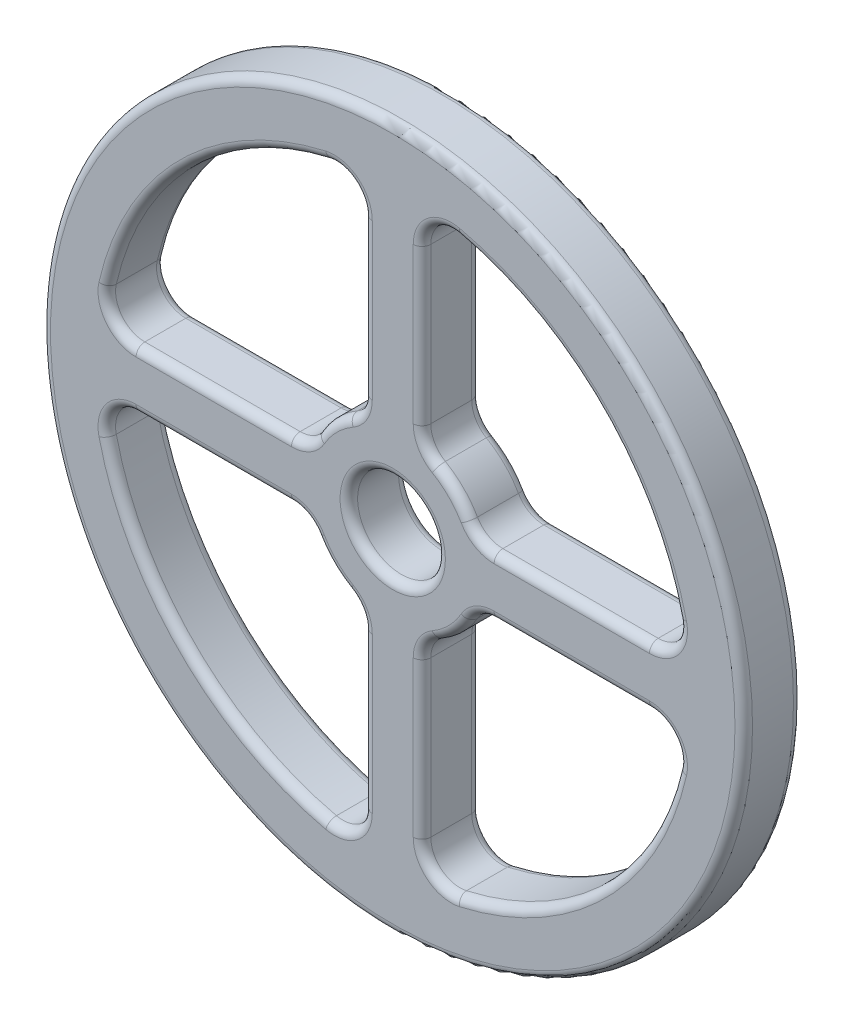
from build123d import *

# Parameters (mm, degrees)
SKETCH2_R               = 120
SKETCH2_R_2             = 15
BOSS_EXTRUDE1_DEPTH     = 10
CUT_EXTRUDE1_DEPTH      = 1
CUT_EXTRUDE1_DEPTH_BACK = 21
FILLET1_R               = 3


with BuildPart() as part:
    # Sketch2 → Boss-Extrude1 (new body, symmetric)
    with BuildSketch(Plane.XY):
        Circle(SKETCH2_R)
        Circle(SKETCH2_R_2, mode=Mode.SUBTRACT)
    extrude(amount=BOSS_EXTRUDE1_DEPTH, both=True)

    # Sketch3 → Cut-Extrude1 (cut, two sides)
    with BuildSketch(Plane.XY.offset(10)) as cut_extrude1_sk:
        with BuildLine():
            Line((-10, -87.749643874), (-10, -34.641016151))
            ThreePointArc((-10, -34.641016151), (-11.339745962, -29.641016151), (-15, -25.980762114))
            ThreePointArc((-15, -25.980762114), (-21.213203436, -21.213203436), (-25.980762114, -15))
            ThreePointArc((-25.980762114, -15), (-29.641016151, -11.339745962), (-34.641016151, -10))
            Line((-34.641016151, -10), (-87.749643874, -10))
            ThreePointArc((-87.749643874, -10), (-95.567003474, -13.763904355), (-97.499604304, -22.222222222))
            ThreePointArc((-97.499604304, -22.222222222), (-70.710678119, -70.710678119), (-22.222222222, -97.499604304))
            ThreePointArc((-22.222222222, -97.499604304), (-13.763904355, -95.567003474), (-10, -87.749643874))
        make_face()
        with BuildLine():
            Line((10, -87.749643874), (10, -34.641016151))
            ThreePointArc((10, -34.641016151), (11.339745962, -29.641016151), (15, -25.980762114))
            ThreePointArc((15, -25.980762114), (21.213203436, -21.213203436), (25.980762114, -15))
            ThreePointArc((25.980762114, -15), (29.641016151, -11.339745962), (34.641016151, -10))
            Line((34.641016151, -10), (87.749643874, -10))
            ThreePointArc((87.749643874, -10), (95.567003474, -13.763904355), (97.499604304, -22.222222222))
            ThreePointArc((97.499604304, -22.222222222), (70.710678119, -70.710678119), (22.222222222, -97.499604304))
            ThreePointArc((22.222222222, -97.499604304), (13.763904355, -95.567003474), (10, -87.749643874))
        make_face()
        with BuildLine():
            Line((10, 87.749643874), (10, 34.641016151))
            ThreePointArc((10, 34.641016151), (11.339745962, 29.641016151), (15, 25.980762114))
            ThreePointArc((15, 25.980762114), (21.213203436, 21.213203436), (25.980762114, 15))
            ThreePointArc((25.980762114, 15), (29.641016151, 11.339745962), (34.641016151, 10))
            Line((34.641016151, 10), (87.749643874, 10))
            ThreePointArc((87.749643874, 10), (95.567003474, 13.763904355), (97.499604304, 22.222222222))
            ThreePointArc((97.499604304, 22.222222222), (70.710678119, 70.710678119), (22.222222222, 97.499604304))
            ThreePointArc((22.222222222, 97.499604304), (13.763904355, 95.567003474), (10, 87.749643874))
        make_face()
        with BuildLine():
            Line((-34.641016151, 10), (-87.749643874, 10))
            ThreePointArc((-87.749643874, 10), (-95.567003474, 13.763904355), (-97.499604304, 22.222222222))
            ThreePointArc((-97.499604304, 22.222222222), (-70.710678119, 70.710678119), (-22.222222222, 97.499604304))
            ThreePointArc((-22.222222222, 97.499604304), (-13.763904355, 95.567003474), (-10, 87.749643874))
            Line((-10, 87.749643874), (-10, 34.641016151))
            ThreePointArc((-10, 34.641016151), (-11.339745962, 29.641016151), (-15, 25.980762114))
            ThreePointArc((-15, 25.980762114), (-21.213203436, 21.213203436), (-25.980762114, 15))
            ThreePointArc((-25.980762114, 15), (-29.641016151, 11.339745962), (-34.641016151, 10))
        make_face()
    extrude(amount=CUT_EXTRUDE1_DEPTH, mode=Mode.SUBTRACT)
    extrude(cut_extrude1_sk.sketch, amount=-CUT_EXTRUDE1_DEPTH_BACK, mode=Mode.SUBTRACT)

    # Fillet1
    fillet1_edges = [part.edges().sort_by_distance(p)[0] for p in [
        (-120, 0, -10),
        (-13.763904355, 95.567003474, 10),
        (-11.339745962, 29.641016151, 10),
        (-21.213203436, 21.213203436, 10),
        (-29.641016151, 11.339745962, 10),
        (-95.567003474, 13.763904355, 10),
        (-70.710678119, 70.710678119, 10),
        (-13.763904355, 95.567003474, -10),
        (-10, 61.195330013, -10),
        (-11.339745962, 29.641016151, -10),
        (-21.213203436, 21.213203436, -10),
        (-29.641016151, 11.339745962, -10),
        (-61.195330013, 10, -10),
        (-95.567003474, 13.763904355, -10),
        (-70.710678119, 70.710678119, -10),
        (-61.195330013, 10, 10),
        (-10, 61.195330013, 10),
        (-120, 0, 10),
        (-15, 0, -10),
        (-15, 0, 10),
        (13.763904355, 95.567003474, 10),
        (70.710678119, 70.710678119, 10),
        (95.567003474, 13.763904355, 10),
        (29.641016151, 11.339745962, 10),
        (21.213203436, 21.213203436, 10),
        (11.339745962, 29.641016151, 10),
        (13.763904355, 95.567003474, -10),
        (70.710678119, 70.710678119, -10),
        (95.567003474, 13.763904355, -10),
        (61.195330013, 10, -10),
        (29.641016151, 11.339745962, -10),
        (21.213203436, 21.213203436, -10),
        (11.339745962, 29.641016151, -10),
        (10, 61.195330013, -10),
        (10, 61.195330013, 10),
        (61.195330013, 10, 10),
        (95.567003474, -13.763904355, 10),
        (70.710678119, -70.710678119, 10),
        (13.763904355, -95.567003474, 10),
        (11.339745962, -29.641016151, 10),
        (21.213203436, -21.213203436, 10),
        (29.641016151, -11.339745962, 10),
        (95.567003474, -13.763904355, -10),
        (70.710678119, -70.710678119, -10),
        (13.763904355, -95.567003474, -10),
        (10, -61.195330013, -10),
        (11.339745962, -29.641016151, -10),
        (21.213203436, -21.213203436, -10),
        (29.641016151, -11.339745962, -10),
        (61.195330013, -10, -10),
        (61.195330013, -10, 10),
        (10, -61.195330013, 10),
        (-95.567003474, -13.763904355, 10),
        (-29.641016151, -11.339745962, 10),
        (-21.213203436, -21.213203436, 10),
        (-11.339745962, -29.641016151, 10),
        (-13.763904355, -95.567003474, 10),
        (-70.710678119, -70.710678119, 10),
        (-95.567003474, -13.763904355, -10),
        (-61.195330013, -10, -10),
        (-29.641016151, -11.339745962, -10),
        (-21.213203436, -21.213203436, -10),
        (-11.339745962, -29.641016151, -10),
        (-10, -61.195330013, -10),
        (-13.763904355, -95.567003474, -10),
        (-70.710678119, -70.710678119, -10),
        (-10, -61.195330013, 10),
        (-61.195330013, -10, 10),
    ]]
    fillet(fillet1_edges, radius=FILLET1_R)


solid = part.part
